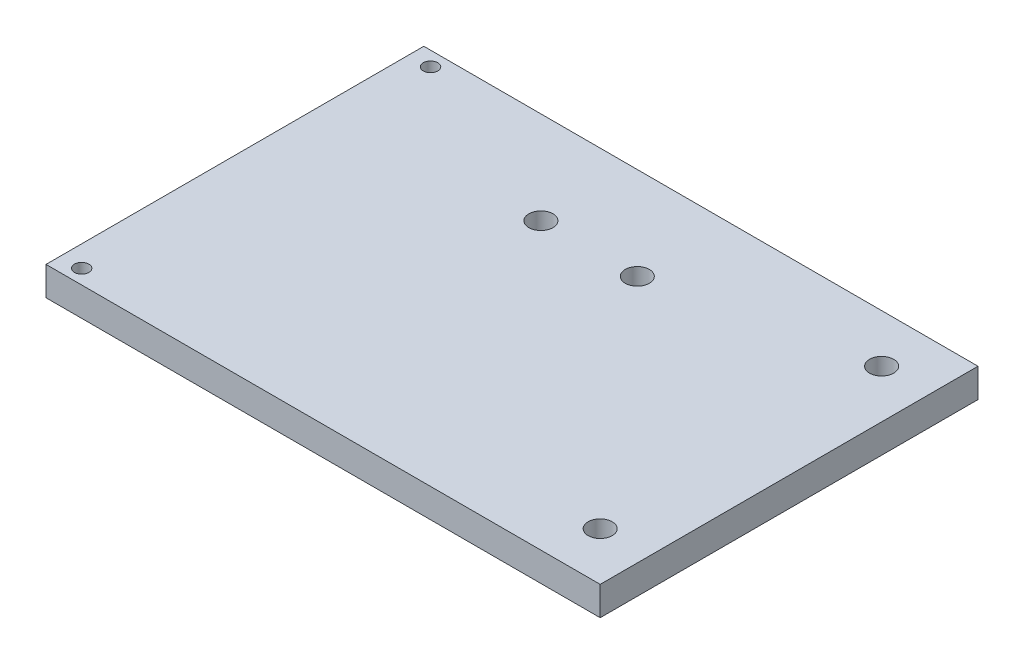
from build123d import *

# Parameters (mm, degrees)
SKETCH1_W           = 115
SKETCH1_H           = 78.4
SKETCH1_R           = 1.5
SKETCH1_R_2         = 2.5
BOSS_EXTRUDE1_DEPTH = 6


with BuildPart() as part:
    # Sketch1 → Boss-Extrude1 (new body)
    with BuildSketch(Plane(origin=(0, 0, 0), x_dir=(1, 0, 0), z_dir=(0, 1, 0))):
        Rectangle(SKETCH1_W, SKETCH1_H)
        with Locations((-53.099489796, 36.2)):
            Circle(SKETCH1_R, mode=Mode.SUBTRACT)
        with Locations((-53.099489796, -36.2)):
            Circle(SKETCH1_R, mode=Mode.SUBTRACT)
        with Locations((47.5, 29.2)):
            Circle(SKETCH1_R_2, mode=Mode.SUBTRACT)
        with Locations((47.5, -29.2)):
            Circle(SKETCH1_R_2, mode=Mode.SUBTRACT)
        with Locations((6, 20)):
            Circle(SKETCH1_R_2, mode=Mode.SUBTRACT)
        with Locations((-14, 20)):
            Circle(SKETCH1_R_2, mode=Mode.SUBTRACT)
    extrude(amount=BOSS_EXTRUDE1_DEPTH)


solid = part.part
